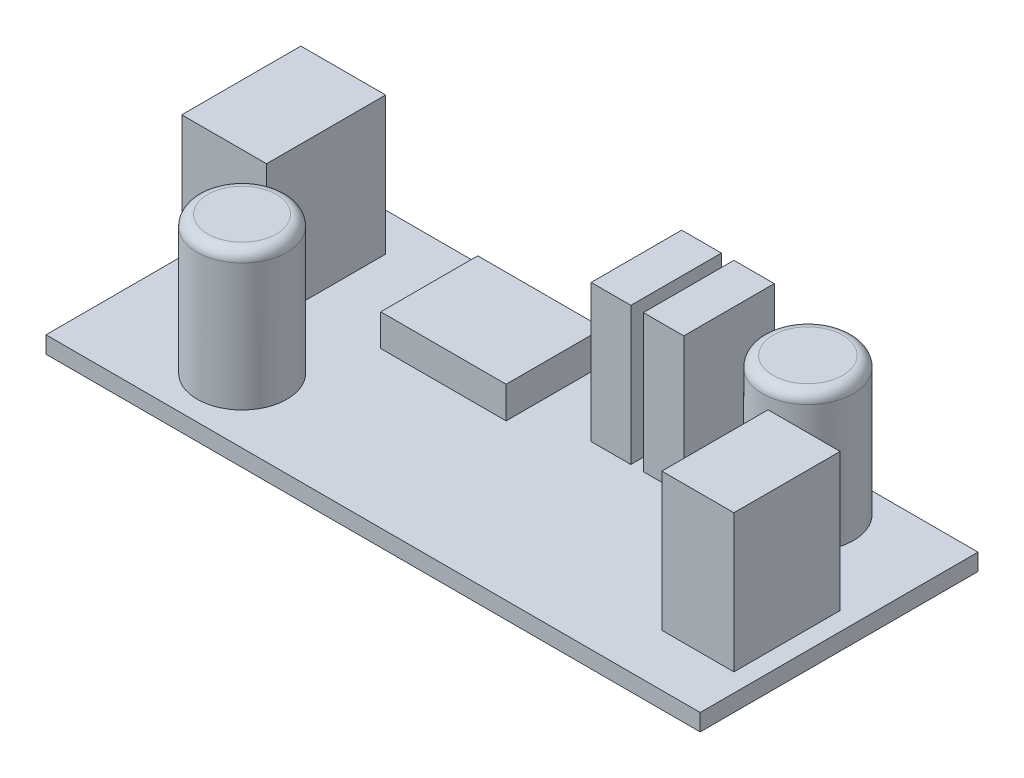
from build123d import *

# Parameters (mm, degrees)
SKETCH1_W           = 61.7
SKETCH1_H           = 26.2
BOSS_EXTRUDE1_DEPTH = 1.59
SKETCH2_R           = 4.284216932
SKETCH2_R_2         = 4.233461823
SKETCH2_W           = 7.996291091
SKETCH2_H           = 11.231630152
SKETCH2_W_2         = 6.79740416
SKETCH2_H_2         = 10.015433833
SKETCH2_W_3         = 3.744475554
SKETCH2_H_3         = 8.537740598
SKETCH2_W_4         = 3.804793914
BOSS_EXTRUDE2_DEPTH = 13
FILLET1_R           = 1
SKETCH3_W           = 11.824805187
SKETCH3_H           = 9.14941117
BOSS_EXTRUDE3_DEPTH = 3


with BuildPart() as part:
    # Sketch1 → Boss-Extrude1 (new body)
    with BuildSketch(Plane(origin=(0, 0, 0), x_dir=(1, 0, 0), z_dir=(0, 1, 0))):
        with Locations((30.85, 13.1)):
            Rectangle(SKETCH1_W, SKETCH1_H)
    extrude(amount=BOSS_EXTRUDE1_DEPTH)

    # Sketch2 → Boss-Extrude2 (add)
    with BuildSketch(Plane(origin=(0, 1.59, 0), x_dir=(1, 0, 0), z_dir=(0, 1, 0))):
        with Locations((50.601195051, 21.255565251)):
            Circle(SKETCH2_R)
        with Locations((12.398624263, 6.095655225)):
            Circle(SKETCH2_R_2)
        with Locations((5.431373533, 16.986694952)):
            Rectangle(SKETCH2_W, SKETCH2_H)
        with Locations((56.574526606, 9.914115999)):
            Rectangle(SKETCH2_W_2, SKETCH2_H_2)
        with Locations((36.301503569, 21.255565251)):
            Rectangle(SKETCH2_W_3, SKETCH2_H_3)
        with Locations((41.260345926, 21.255565251)):
            Rectangle(SKETCH2_W_4, SKETCH2_H_3)
    extrude(amount=BOSS_EXTRUDE2_DEPTH)

    # Fillet1
    fillet1_edges = [part.edges().sort_by_distance(p)[0] for p in [
        (46.316978119, 14.59, -21.255565251),
        (8.16516244, 14.59, -6.095655225),
    ]]
    fillet(fillet1_edges, radius=FILLET1_R)

    # Sketch3 → Boss-Extrude3 (add)
    with BuildSketch(Plane(origin=(0, 1.59, 0), x_dir=(1, 0, 0), z_dir=(0, 1, 0))):
        with Locations((22.821277789, 19.236524015)):
            Rectangle(SKETCH3_W, SKETCH3_H)
    extrude(amount=BOSS_EXTRUDE3_DEPTH)


solid = part.part
